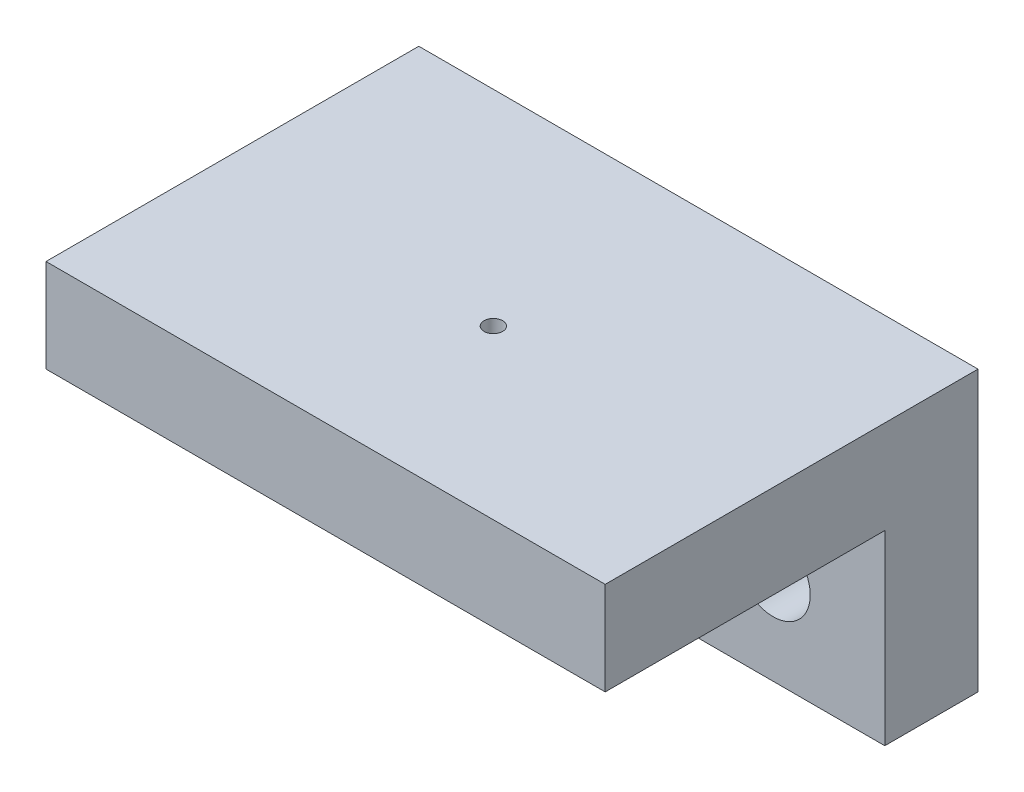
from build123d import *

# Parameters (mm, degrees)
CROQUIS1_W              = 30
CROQUIS1_H              = 15
SALIENTE_EXTRUIR1_DEPTH = 5
CROQUIS2_W              = 30
CROQUIS2_H              = 5
SALIENTE_EXTRUIR2_DEPTH = 15
CROQUIS3_R              = 2
CORTAR_EXTRUIR1_DEPTH   = 15
CROQUIS4_R              = 0.5
CORTAR_EXTRUIR2_DEPTH   = 10


with BuildPart() as part:
    # Croquis1 → Saliente-Extruir1 (new body)
    with BuildSketch(Plane.XY):
        with Locations((15, 7.5)):
            Rectangle(CROQUIS1_W, CROQUIS1_H)
    extrude(amount=SALIENTE_EXTRUIR1_DEPTH)

    # Croquis2 → Saliente-Extruir2 (add)
    with BuildSketch(Plane.XY.offset(5)):
        with Locations((15, 12.5)):
            Rectangle(CROQUIS2_W, CROQUIS2_H)
    extrude(amount=SALIENTE_EXTRUIR2_DEPTH)

    # Croquis3 → Cortar-Extruir1 (cut)
    with BuildSketch(Plane.XY.offset(5)):
        with Locations((24, 5)):
            Circle(CROQUIS3_R)
        with Locations((6, 5)):
            Circle(CROQUIS3_R)
    extrude(amount=-CORTAR_EXTRUIR1_DEPTH, mode=Mode.SUBTRACT)

    # Croquis4 → Cortar-Extruir2 (cut)
    with BuildSketch(Plane(origin=(0, 10, 0), x_dir=(-1, 0, 0), z_dir=(0, -1, 0))):
        with Locations((-15, -11)):
            Circle(CROQUIS4_R)
    extrude(amount=-CORTAR_EXTRUIR2_DEPTH, mode=Mode.SUBTRACT)


solid = part.part
